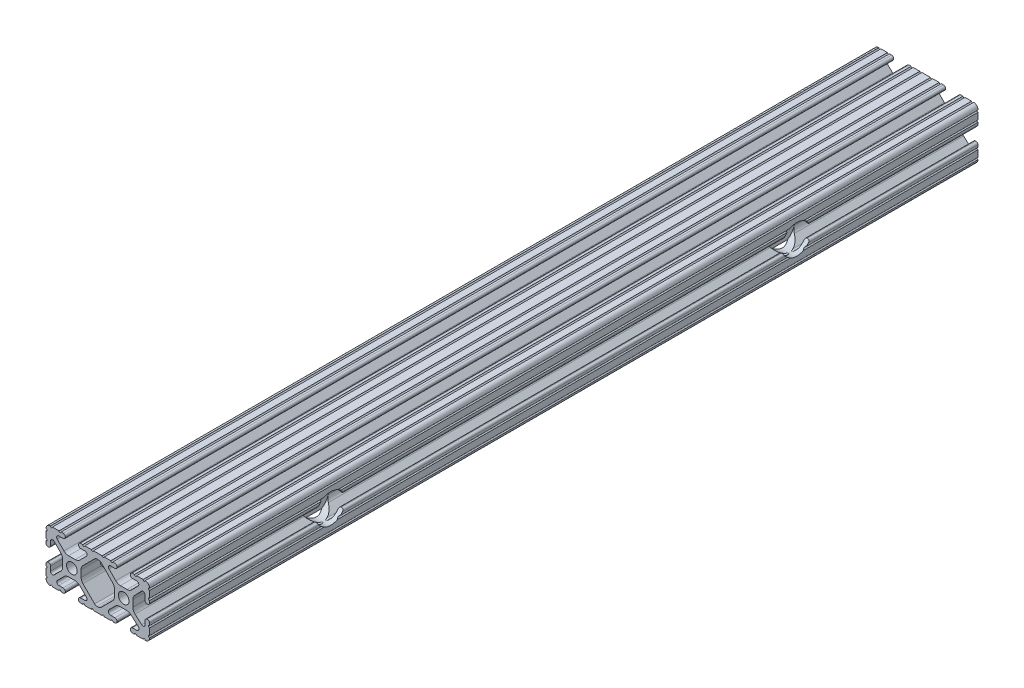
from build123d import *

# Parameters (mm, degrees)
SKETCH1_R                                            = 2.6035
BOSS_EXTRUDE1_DEPTH                                  = 203.2
CBORE_FOR_1_4_BINDING_HEAD_MACHINE_SCREW_D           = 6.7564
CBORE_FOR_1_4_BINDING_HEAD_MACHINE_SCREW_CBORE_D     = 14.2875
CBORE_FOR_1_4_BINDING_HEAD_MACHINE_SCREW_CBORE_DEPTH = 8.255
F_1_4_0_25_DIAMETER_HOLE1_D                          = 6.35
SKETCH10_R                                           = 3.175
CUT_EXTRUDE1_DEPTH                                   = 9.191498223
CUT_EXTRUDE1_DEPTH_BACK                              = 43.608501977


with BuildPart() as part:
    # Sketch1 → Boss-Extrude1 (new body, symmetric)
    with BuildSketch(Plane.XY):
        with BuildLine():
            Line((18.01710265, 12.7), (16.98745015, 12.7))
            ThreePointArc((16.98745015, 12.7), (16.245730386, 12.392769614), (15.9385, 11.65104985))
            Line((15.9385, 11.65104985), (15.9385, 11.53922))
            ThreePointArc((15.9385, 11.53922), (16.245750844, 10.797450844), (16.98752, 10.4902))
            Line((16.98752, 10.4902), (19.116384363, 10.4902))
            ThreePointArc((19.116384363, 10.4902), (20.052502933, 9.869096983), (19.844087081, 8.765172272))
            Line((19.844087081, 8.765172272), (16.618993479, 5.455112286))
            ThreePointArc((16.618993479, 5.455112286), (15.578994274, 4.745442459), (14.344932584, 4.4958))
            Line((14.344932584, 4.4958), (11.083317835, 4.4958))
            ThreePointArc((11.083317835, 4.4958), (9.854330953, 4.743306833), (8.816955189, 5.447238587))
            Line((8.816955189, 5.447238587), (5.564154119, 8.762652677))
            ThreePointArc((5.564154119, 8.762652677), (5.352591412, 9.867473037), (6.289393385, 10.4902))
            Line((6.289393385, 10.4902), (8.41248, 10.4902))
            ThreePointArc((8.41248, 10.4902), (9.154249156, 10.797450844), (9.4615, 11.53922))
            Line((9.4615, 11.53922), (9.4615, 11.65104985))
            ThreePointArc((9.4615, 11.65104985), (9.154269614, 12.392769614), (8.41254985, 12.7))
            Line((8.41254985, 12.7), (7.38288465, 12.7))
            ThreePointArc((7.38288465, 12.7), (6.87488465, 12.192), (6.36688465, 12.7))
            Line((6.36688465, 12.7), (3.14958095, 12.7))
            ThreePointArc((3.14958095, 12.7), (2.64158095, 12.192), (2.13358095, 12.7))
            Line((2.13358095, 12.7), (-2.13358095, 12.7))
            ThreePointArc((-2.13358095, 12.7), (-2.64158095, 12.192), (-3.14958095, 12.7))
            Line((-3.14958095, 12.7), (-6.36689735, 12.7))
            ThreePointArc((-6.36689735, 12.7), (-6.87489735, 12.192), (-7.38289735, 12.7))
            Line((-7.38289735, 12.7), (-8.41254985, 12.7))
            ThreePointArc((-8.41254985, 12.7), (-9.154269614, 12.392769614), (-9.4615, 11.65104985))
            Line((-9.4615, 11.65104985), (-9.4615, 11.53922))
            ThreePointArc((-9.4615, 11.53922), (-9.154249156, 10.797450844), (-8.41248, 10.4902))
            Line((-8.41248, 10.4902), (-6.283641037, 10.4902))
            ThreePointArc((-6.283641037, 10.4902), (-5.297291557, 9.829633109), (-5.532576693, 8.666071843))
            Line((-5.532576693, 8.666071843), (-8.809985098, 5.416263103))
            ThreePointArc((-8.809985098, 5.416263103), (-9.836720513, 4.734920264), (-11.045536121, 4.4958))
            Line((-11.045536121, 4.4958), (-14.354463879, 4.4958))
            ThreePointArc((-14.354463879, 4.4958), (-15.563279487, 4.734920264), (-16.590014902, 5.416263103))
            Line((-16.590014902, 5.416263103), (-19.867423307, 8.666071843))
            ThreePointArc((-19.867423307, 8.666071843), (-20.102708443, 9.829633109), (-19.116358963, 10.4902))
            Line((-19.116358963, 10.4902), (-16.98752, 10.4902))
            ThreePointArc((-16.98752, 10.4902), (-16.245750844, 10.797450844), (-15.9385, 11.53922))
            Line((-15.9385, 11.53922), (-15.9385, 11.65104985))
            ThreePointArc((-15.9385, 11.65104985), (-16.245730386, 12.392769614), (-16.98745015, 12.7))
            Line((-16.98745015, 12.7), (-18.01711535, 12.7))
            ThreePointArc((-18.01711535, 12.7), (-18.52511535, 12.192), (-19.03311535, 12.7))
            Line((-19.03311535, 12.7), (-22.2504, 12.7))
            ThreePointArc((-22.2504, 12.7), (-22.758323491, 12.192000006), (-23.266399977, 12.699846982))
            ThreePointArc((-23.266399977, 12.699846982), (-24.782522516, 12.082522516), (-25.399846982, 10.566399977))
            ThreePointArc((-25.399846982, 10.566399977), (-24.892000006, 10.058323491), (-25.4, 9.5504))
            Line((-25.4, 9.5504), (-25.4, 6.3330836))
            ThreePointArc((-25.4, 6.3330836), (-24.892, 5.8250836), (-25.4, 5.3170836))
            Line((-25.4, 5.3170836), (-25.4, 4.237520184))
            ThreePointArc((-25.4, 4.237520184), (-25.107393763, 3.531106237), (-24.400979816, 3.2385))
            Line((-24.400979816, 3.2385), (-24.23922, 3.2385))
            ThreePointArc((-24.23922, 3.2385), (-23.497450844, 3.545750844), (-23.1902, 4.28752))
            Line((-23.1902, 4.28752), (-23.1902, 6.334741132))
            ThreePointArc((-23.1902, 6.334741132), (-22.556026952, 7.286023527), (-21.434002553, 7.066535717))
            Line((-21.434002553, 7.066535717), (-18.147950853, 3.808156468))
            ThreePointArc((-18.147950853, 3.808156468), (-17.452759693, 2.774838327), (-17.208501877, 1.553619571))
            Line((-17.208501877, 1.553619571), (-17.208501877, -1.695179196))
            ThreePointArc((-17.208501877, -1.695179196), (-17.450738657, -2.911536421), (-18.140486065, -3.942289578))
            Line((-18.140486065, -3.942289578), (-21.431579576, -7.227386226))
            ThreePointArc((-21.431579576, -7.227386226), (-22.55444896, -7.449940594), (-23.1902, -6.498002195))
            Line((-23.1902, -6.498002195), (-23.1902, -4.28752))
            ThreePointArc((-23.1902, -4.28752), (-23.497450844, -3.545750844), (-24.23922, -3.2385))
            Line((-24.23922, -3.2385), (-24.35098, -3.2385))
            ThreePointArc((-24.35098, -3.2385), (-25.092749156, -3.545750844), (-25.4, -4.28752))
            Line((-25.4, -4.28752), (-25.4, -5.3171344))
            ThreePointArc((-25.4, -5.3171344), (-24.892, -5.8251344), (-25.4, -6.3331344))
            Line((-25.4, -6.3331344), (-25.4, -9.5504))
            ThreePointArc((-25.4, -9.5504), (-24.892000006, -10.058323491), (-25.399846982, -10.566399977))
            ThreePointArc((-25.399846982, -10.566399977), (-24.782522516, -12.082522516), (-23.266399977, -12.699846982))
            ThreePointArc((-23.266399977, -12.699846982), (-22.758323491, -12.192000006), (-22.2504, -12.7))
            Line((-22.2504, -12.7), (-19.03308995, -12.7))
            ThreePointArc((-19.03308995, -12.7), (-18.52508995, -12.192), (-18.01708995, -12.7))
            Line((-18.01708995, -12.7), (-16.9874692, -12.7))
            ThreePointArc((-16.9874692, -12.7), (-16.245700044, -12.392749156), (-15.9384492, -11.65098))
            Line((-15.9384492, -11.65098), (-15.9384492, -11.53922))
            ThreePointArc((-15.9384492, -11.53922), (-16.245700044, -10.797450844), (-16.9874692, -10.4902))
            Line((-16.9874692, -10.4902), (-19.116358963, -10.4902))
            ThreePointArc((-19.116358963, -10.4902), (-20.055197748, -9.862578342), (-19.834124023, -8.755124678))
            Line((-19.834124023, -8.755124678), (-16.49660751, -5.423689618))
            ThreePointArc((-16.49660751, -5.423689618), (-15.467274017, -4.736928798), (-14.253591699, -4.4958))
            Line((-14.253591699, -4.4958), (-11.146408301, -4.4958))
            ThreePointArc((-11.146408301, -4.4958), (-9.932725983, -4.736928798), (-8.90339249, -5.423689618))
            Line((-8.90339249, -5.423689618), (-5.565875977, -8.755124678))
            ThreePointArc((-5.565875977, -8.755124678), (-5.344802252, -9.862578342), (-6.283641037, -10.4902))
            Line((-6.283641037, -10.4902), (-8.4125308, -10.4902))
            ThreePointArc((-8.4125308, -10.4902), (-9.154299956, -10.797450844), (-9.4615508, -11.53922))
            Line((-9.4615508, -11.53922), (-9.4615508, -11.65098))
            ThreePointArc((-9.4615508, -11.65098), (-9.154299956, -12.392749156), (-8.4125308, -12.7))
            Line((-8.4125308, -12.7), (-7.38287195, -12.7))
            ThreePointArc((-7.38287195, -12.7), (-6.87487195, -12.192), (-6.36687195, -12.7))
            Line((-6.36687195, -12.7), (-3.14960635, -12.7))
            ThreePointArc((-3.14960635, -12.7), (-2.64160635, -12.192), (-2.13360635, -12.7))
            Line((-2.13360635, -12.7), (2.13360635, -12.7))
            ThreePointArc((2.13360635, -12.7), (2.64159365, -12.1920127), (3.14958095, -12.7))
            Line((3.14958095, -12.7), (6.36691005, -12.7))
            ThreePointArc((6.36691005, -12.7), (6.87491005, -12.192), (7.38291005, -12.7))
            Line((7.38291005, -12.7), (8.4125308, -12.7))
            ThreePointArc((8.4125308, -12.7), (9.154299956, -12.392749156), (9.4615508, -11.65098))
            Line((9.4615508, -11.65098), (9.4615508, -11.53922))
            ThreePointArc((9.4615508, -11.53922), (9.154299956, -10.797450844), (8.4125308, -10.4902))
            Line((8.4125308, -10.4902), (6.289393385, -10.4902))
            ThreePointArc((6.289393385, -10.4902), (5.231590322, -9.783049717), (5.480677245, -8.535265862))
            Line((5.480677245, -8.535265862), (8.597933595, -5.423689618))
            ThreePointArc((8.597933595, -5.423689618), (9.627267088, -4.736928798), (10.840949406, -4.4958))
            Line((10.840949406, -4.4958), (14.102564155, -4.4958))
            ThreePointArc((14.102564155, -4.4958), (15.215927525, -4.697410182), (16.187895372, -5.276636531))
            Line((16.187895372, -5.276636531), (19.868247549, -8.482246082))
            ThreePointArc((19.868247549, -8.482246082), (20.188435806, -9.746879864), (19.116384363, -10.4902))
            Line((19.116384363, -10.4902), (16.9874692, -10.4902))
            ThreePointArc((16.9874692, -10.4902), (16.245700044, -10.797450844), (15.9384492, -11.53922))
            Line((15.9384492, -11.53922), (15.9384492, -11.65098))
            ThreePointArc((15.9384492, -11.65098), (16.245700044, -12.392749156), (16.9874692, -12.7))
            Line((16.9874692, -12.7), (18.01710265, -12.7))
            ThreePointArc((18.01710265, -12.7), (18.52510265, -12.192), (19.03310265, -12.7))
            Line((19.03310265, -12.7), (22.2504, -12.7))
            ThreePointArc((22.2504, -12.7), (22.758323491, -12.192000006), (23.266399977, -12.699846982))
            ThreePointArc((23.266399977, -12.699846982), (24.782522516, -12.082522516), (25.399846982, -10.566399977))
            ThreePointArc((25.399846982, -10.566399977), (24.892000006, -10.058323492), (25.4, -9.550400001))
            Line((25.4, -9.550400001), (25.4, -6.333083592))
            ThreePointArc((25.4, -6.333083592), (24.892000001, -5.825083593), (25.4, -5.317083593))
            Line((25.4, -5.317083593), (25.4, -4.237520184))
            ThreePointArc((25.4, -4.237520184), (25.107393763, -3.531106237), (24.400979816, -3.2385))
            Line((24.400979816, -3.2385), (24.189220184, -3.2385))
            ThreePointArc((24.189220184, -3.2385), (23.482806237, -3.531106237), (23.1902, -4.237520184))
            Line((23.1902, -4.237520184), (23.1902, -6.155876159))
            ThreePointArc((23.1902, -6.155876159), (22.62232736, -7.038258539), (21.583974541, -6.886926384))
            Line((21.583974541, -6.886926384), (18.29817066, -4.024970844))
            ThreePointArc((18.29817066, -4.024970844), (17.493730985, -2.946044689), (17.208501877, -1.630807374))
            Line((17.208501877, -1.630807374), (17.208501877, 1.630807374))
            ThreePointArc((17.208501877, 1.630807374), (17.442348332, 2.82673414), (18.109440981, 3.846495088))
            Line((18.109440981, 3.846495088), (21.526346532, 7.353420386))
            ThreePointArc((21.526346532, 7.353420386), (22.585896263, 7.574939077), (23.1902, 6.676867167))
            Line((23.1902, 6.676867167), (23.1902, 4.237520184))
            ThreePointArc((23.1902, 4.237520184), (23.482806237, 3.531106237), (24.189220184, 3.2385))
            Line((24.189220184, 3.2385), (24.400979816, 3.2385))
            ThreePointArc((24.400979816, 3.2385), (25.107393763, 3.531106237), (25.4, 4.237520184))
            Line((25.4, 4.237520184), (25.4, 5.3170836))
            ThreePointArc((25.4, 5.3170836), (24.891949193, 5.825134407), (25.4, 6.333185215))
            Line((25.4, 6.333185215), (25.4, 9.550400015))
            ThreePointArc((25.4, 9.550400015), (24.892000013, 10.058323498), (25.399846982, 10.566399977))
            ThreePointArc((25.399846982, 10.566399977), (24.782522516, 12.082522516), (23.266399977, 12.699846982))
            ThreePointArc((23.266399977, 12.699846982), (22.758323491, 12.192000006), (22.2504, 12.7))
            Line((22.2504, 12.7), (19.03310265, 12.7))
            ThreePointArc((19.03310265, 12.7), (18.52510265, 12.192), (18.01710265, 12.7))
        make_face()
        with Locations((-12.7, 0)):
            Circle(SKETCH1_R, mode=Mode.SUBTRACT)
        with Locations((12.7, 0)):
            Circle(SKETCH1_R, mode=Mode.SUBTRACT)
        with BuildLine():
            Line((-7.259513935, -3.869413038), (-1.545748891, -9.572766749))
            ThreePointArc((-1.545748891, -9.572766749), (-1.035199478, -9.913400116), (-0.433213048, -10.033))
            Line((-0.433213048, -10.033), (0.433213048, -10.033))
            ThreePointArc((0.433213048, -10.033), (1.035199478, -9.913400116), (1.545748891, -9.572766749))
            Line((1.545748891, -9.572766749), (7.259513935, -3.869413038))
            ThreePointArc((7.259513935, -3.869413038), (7.949261343, -2.838659881), (8.191498123, -1.622302656))
            Line((8.191498123, -1.622302656), (8.191498123, 1.622302656))
            ThreePointArc((8.191498123, 1.622302656), (7.955573352, 2.823327967), (7.282860769, 3.845864069))
            Line((7.282860769, 3.845864069), (1.675572808, 9.561086461))
            ThreePointArc((1.675572808, 9.561086461), (1.161034429, 9.910236611), (0.551456936, 10.033))
            Line((0.551456936, 10.033), (-0.395199982, 10.033))
            ThreePointArc((-0.395199982, 10.033), (-0.994772524, 9.914396349), (-1.50403329, 9.576450301))
            Line((-1.50403329, 9.576450301), (-7.252049147, 3.876839553))
            ThreePointArc((-7.252049147, 3.876839553), (-7.947240307, 2.843521412), (-8.191498123, 1.622302656))
            Line((-8.191498123, 1.622302656), (-8.191498123, -1.622302656))
            ThreePointArc((-8.191498123, -1.622302656), (-7.949261343, -2.838659881), (-7.259513935, -3.869413038))
        make_face(mode=Mode.SUBTRACT)
    extrude(amount=BOSS_EXTRUDE1_DEPTH, both=True)

    # CBORE for 1/4 Binding Head Machine Screw1 (through all)
    with Locations(Plane(origin=(25.4, 0, 0), x_dir=(0, 0, -1), z_dir=(1, 0, 0))):
        with Locations((-114.3, 0), (114.3, 0)):
            CounterBoreHole(CBORE_FOR_1_4_BINDING_HEAD_MACHINE_SCREW_D / 2, CBORE_FOR_1_4_BINDING_HEAD_MACHINE_SCREW_CBORE_D / 2, CBORE_FOR_1_4_BINDING_HEAD_MACHINE_SCREW_CBORE_DEPTH)

    # 1/4 (0.25) Diameter Hole1 (through all)
    with Locations(Plane(origin=(25.4, 0, 0), x_dir=(0, 0, -1), z_dir=(1, 0, 0))):
        with Locations((-76.2, 0), (76.2, 0)):
            Hole(F_1_4_0_25_DIAMETER_HOLE1_D / 2)

    # Sketch10 → Cut-Extrude1 (cut, two sides)
    with BuildSketch(Plane(origin=(17.208501877, 0, 0), x_dir=(0, 0, -1), z_dir=(1, 0, 0))) as cut_extrude1_sk:
        with Locations((-190.5, 0)):
            Circle(SKETCH10_R)
        with Locations((190.5, 0)):
            Circle(SKETCH10_R)
    extrude(amount=CUT_EXTRUDE1_DEPTH, mode=Mode.SUBTRACT)
    extrude(cut_extrude1_sk.sketch, amount=-CUT_EXTRUDE1_DEPTH_BACK, mode=Mode.SUBTRACT)


solid = part.part
